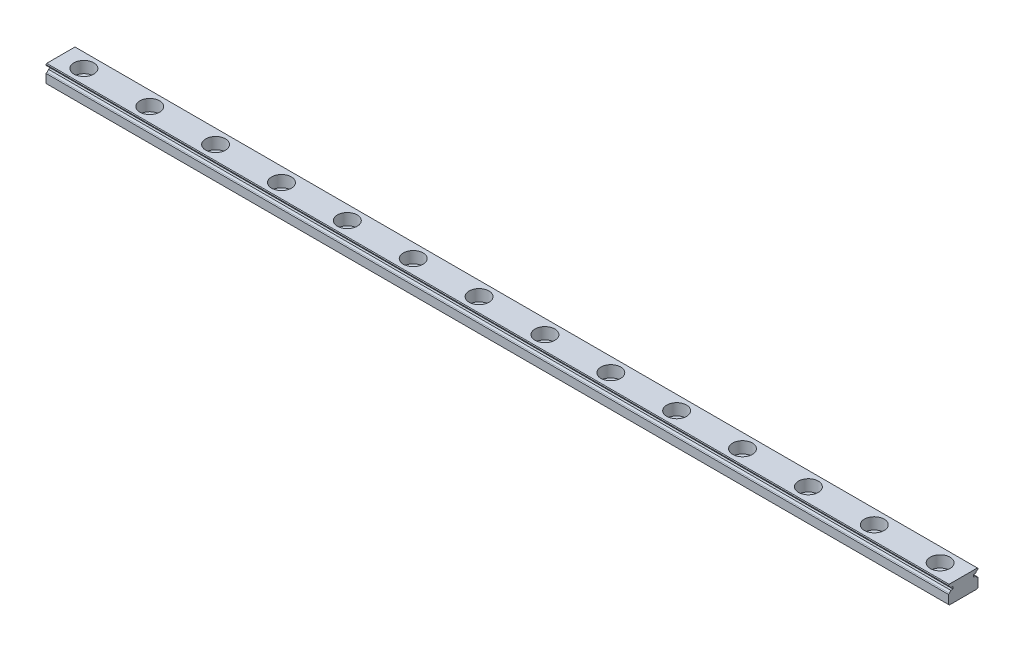
from build123d import *

# Parameters (mm, degrees)
SKETCH1_W                                    = 9
SKETCH1_H                                    = 5.5
BOSS_EXTRUDE1_DEPTH                          = 274
CUT_EXTRUDE2_DEPTH                           = 275
CBORE_FOR_SOCKET_HEAD_CAP_SCREW1_D           = 3.5
CBORE_FOR_SOCKET_HEAD_CAP_SCREW1_CBORE_D     = 6
CBORE_FOR_SOCKET_HEAD_CAP_SCREW1_CBORE_DEPTH = 3.5
LPATTERN1_COUNT                              = 14
LPATTERN1_PITCH                              = 20
CHAMFER1_SIZE                                = 0.2
CHAMFER2_SIZE                                = 0.3


with BuildPart() as part:
    # Sketch1 → Boss-Extrude1 (new body)
    with BuildSketch(Plane(origin=(-7, 0, 0), x_dir=(0, 0, -1), z_dir=(1, 0, 0))):
        with Locations((0, 2.75)):
            Rectangle(SKETCH1_W, SKETCH1_H)
    extrude(amount=BOSS_EXTRUDE1_DEPTH)

    # Sketch3 → Cut-Extrude2 (cut, through all)
    with BuildSketch(Plane(origin=(-7, 0, 0), x_dir=(0, 0, -1), z_dir=(1, 0, 0))):
        with BuildLine():
            Line((4.5, 5.04428602), (4.22, 4.882627944))
            ThreePointArc((4.22, 4.882627944), (3.942636741, 4.654893122), (3.753338798, 4.35))
            Line((3.753338798, 4.35), (3.1, 4.35))
            Line((3.1, 4.35), (3.1, 3.65))
            Line((3.1, 3.65), (3.753338798, 3.65))
            ThreePointArc((3.753338798, 3.65), (3.942636741, 3.345106878), (4.22, 3.117372056))
            Line((4.22, 3.117372056), (4.5, 2.95571398))
            Line((4.5, 2.95571398), (4.5, 5.04428602))
        make_face()
        with BuildLine():
            Line((-4.5, 5.04428602), (-4.5, 2.95571398))
            Line((-4.5, 2.95571398), (-4.22, 3.117372056))
            ThreePointArc((-4.22, 3.117372056), (-3.942636741, 3.345106878), (-3.753338798, 3.65))
            Line((-3.753338798, 3.65), (-3.1, 3.65))
            Line((-3.1, 3.65), (-3.1, 4.35))
            Line((-3.1, 4.35), (-3.753338798, 4.35))
            ThreePointArc((-3.753338798, 4.35), (-3.942636741, 4.654893122), (-4.22, 4.882627944))
            Line((-4.22, 4.882627944), (-4.5, 5.04428602))
        make_face()
    extrude(amount=CUT_EXTRUDE2_DEPTH, mode=Mode.SUBTRACT)

    # CBORE for Socket Head Cap Screw1 (through all)
    with Locations(Plane(origin=(0, 5.5, 0), x_dir=(1, 0, 0), z_dir=(0, 1, 0))):
        with Locations((0, 0)):
            cbore_for_socket_head_cap_screw1 = CounterBoreHole(CBORE_FOR_SOCKET_HEAD_CAP_SCREW1_D / 2, CBORE_FOR_SOCKET_HEAD_CAP_SCREW1_CBORE_D / 2, CBORE_FOR_SOCKET_HEAD_CAP_SCREW1_CBORE_DEPTH)

    # LPattern1: CBORE for Socket Head Cap Screw1 ×14
    with Locations(*[(i * LPATTERN1_PITCH, 0, 0) for i in range(1, LPATTERN1_COUNT)]):
        add(cbore_for_socket_head_cap_screw1, mode=Mode.SUBTRACT)

    # Chamfer1
    chamfer1_edges = [part.edges().sort_by_distance(p)[0] for p in [
        (130, 5.5, 4.5),
        (130, 5.5, -4.5),
    ]]
    chamfer(chamfer1_edges, length=CHAMFER1_SIZE)

    # Chamfer2
    chamfer2_edges = [part.edges().sort_by_distance(p)[0] for p in [
        (130, 0, -4.5),
        (130, 0, 4.5),
    ]]
    chamfer(chamfer2_edges, length=CHAMFER2_SIZE)


solid = part.part
